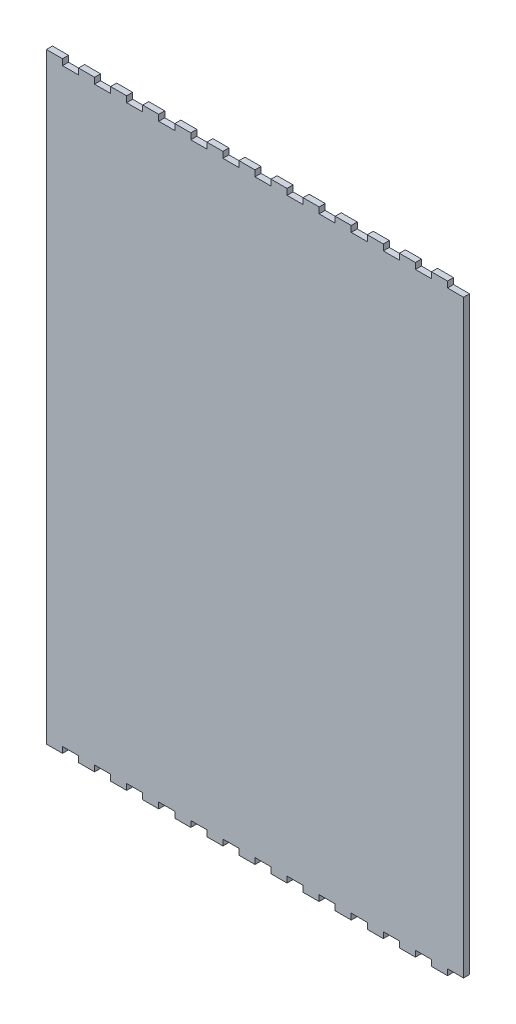
from build123d import *

# Parameters (mm, degrees)
ESQUISSE1_W             = 208
ESQUISSE1_H             = 300
BOSS_EXTRU_1_DEPTH      = 3
ESQUISSE2_W             = 8
ESQUISSE2_H             = 3
ENL_V_MAT_EXTRU_1_DEPTH = 3


with BuildPart() as part:
    # Esquisse1 → Boss.-Extru.1 (new body)
    with BuildSketch(Plane.XY):
        Rectangle(ESQUISSE1_W, ESQUISSE1_H)
    extrude(amount=BOSS_EXTRU_1_DEPTH)

    # Esquisse2 → Enlèv. mat.-Extru.1 (cut)
    with BuildSketch(Plane.XY.offset(3)):
        with Locations((-92, 148.5)):
            Rectangle(ESQUISSE2_W, ESQUISSE2_H)
        with Locations((-76, 148.5)):
            Rectangle(ESQUISSE2_W, ESQUISSE2_H)
        with Locations((-60, 148.5)):
            Rectangle(ESQUISSE2_W, ESQUISSE2_H)
        with Locations((-44, 148.5)):
            Rectangle(ESQUISSE2_W, ESQUISSE2_H)
        with Locations((-28, 148.5)):
            Rectangle(ESQUISSE2_W, ESQUISSE2_H)
        with Locations((-12, 148.5)):
            Rectangle(ESQUISSE2_W, ESQUISSE2_H)
        with Locations((4, 148.5)):
            Rectangle(ESQUISSE2_W, ESQUISSE2_H)
        with Locations((20, 148.5)):
            Rectangle(ESQUISSE2_W, ESQUISSE2_H)
        with Locations((36, 148.5)):
            Rectangle(ESQUISSE2_W, ESQUISSE2_H)
        with Locations((52, 148.5)):
            Rectangle(ESQUISSE2_W, ESQUISSE2_H)
        with Locations((68, 148.5)):
            Rectangle(ESQUISSE2_W, ESQUISSE2_H)
        with Locations((84, 148.5)):
            Rectangle(ESQUISSE2_W, ESQUISSE2_H)
        with Locations((100, 148.5)):
            Rectangle(ESQUISSE2_W, ESQUISSE2_H)
        with Locations((100, -148.5)):
            Rectangle(ESQUISSE2_W, ESQUISSE2_H)
        with Locations((84, -148.5)):
            Rectangle(ESQUISSE2_W, ESQUISSE2_H)
        with Locations((68, -148.5)):
            Rectangle(ESQUISSE2_W, ESQUISSE2_H)
        with Locations((52, -148.5)):
            Rectangle(ESQUISSE2_W, ESQUISSE2_H)
        with Locations((36, -148.5)):
            Rectangle(ESQUISSE2_W, ESQUISSE2_H)
        with Locations((20, -148.5)):
            Rectangle(ESQUISSE2_W, ESQUISSE2_H)
        with Locations((4, -148.5)):
            Rectangle(ESQUISSE2_W, ESQUISSE2_H)
        with Locations((-12, -148.5)):
            Rectangle(ESQUISSE2_W, ESQUISSE2_H)
        with Locations((-28, -148.5)):
            Rectangle(ESQUISSE2_W, ESQUISSE2_H)
        with Locations((-44, -148.5)):
            Rectangle(ESQUISSE2_W, ESQUISSE2_H)
        with Locations((-60, -148.5)):
            Rectangle(ESQUISSE2_W, ESQUISSE2_H)
        with Locations((-76, -148.5)):
            Rectangle(ESQUISSE2_W, ESQUISSE2_H)
        with Locations((-92, -148.5)):
            Rectangle(ESQUISSE2_W, ESQUISSE2_H)
    extrude(amount=-ENL_V_MAT_EXTRU_1_DEPTH, mode=Mode.SUBTRACT)


solid = part.part
